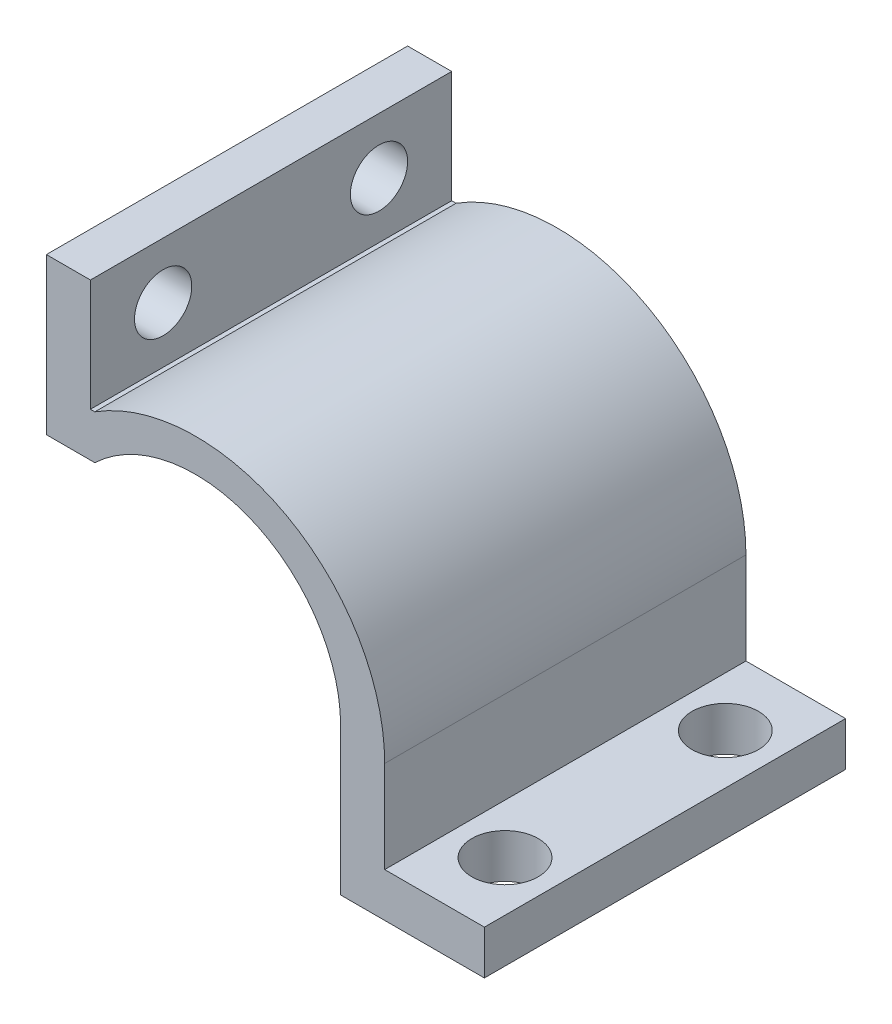
from build123d import *

# Parameters (mm, degrees)
BOSS_EXTRUDE1_DEPTH = 82
SKETCH3_R           = 7.537472245
CUT_EXTRUDE2_DEPTH  = 11
SKETCH4_R           = 6.5
CUT_EXTRUDE3_DEPTH  = 11


with BuildPart() as part:
    # Sketch1 → Boss-Extrude1 (new body)
    with BuildSketch(Plane.XY):
        with BuildLine():
            Line((33.003348812, 0), (33.003348812, -33.227979662))
            Line((33.003348812, -33.227979662), (65.632108119, -33.227979662))
            Line((65.632108119, -33.227979662), (65.632108119, -23.227979662))
            Line((65.632108119, -23.227979662), (43.003348812, -23.227979662))
            Line((43.003348812, -23.227979662), (43.003348812, -2.369569967))
            ThreePointArc((43.003348812, -2.369569967), (20.809611253, 35.186501293), (-22.793831907, 33.859768466))
            Line((-22.793831907, 33.859768466), (-23.793831907, 33.859768466))
            Line((-23.793831907, 33.859768466), (-23.793831907, 59.275147612))
            Line((-23.793831907, 59.275147612), (-33.793831907, 59.275147612))
            Line((-33.793831907, 59.275147612), (-33.793831907, 23.859768466))
            Line((-33.793831907, 23.859768466), (-22.793831907, 23.859768466))
            ThreePointArc((-22.793831907, 23.859768466), (12.978190551, 30.342272193), (33.003348812, 0))
        make_face()
    extrude(amount=-BOSS_EXTRUDE1_DEPTH)

    # Sketch3 → Cut-Extrude2 (cut, through all)
    with BuildSketch(Plane(origin=(0, -23.227979662, 0), x_dir=(1, 0, 0), z_dir=(0, 1, 0))):
        with Locations((54.317728466, 16)):
            Circle(SKETCH3_R)
        with Locations((54.317728466, 66)):
            Circle(SKETCH3_R)
    extrude(amount=-CUT_EXTRUDE2_DEPTH, mode=Mode.SUBTRACT)

    # Sketch4 → Cut-Extrude3 (cut, through all)
    with BuildSketch(Plane(origin=(-23.793831907, 0, 0), x_dir=(0, 0, -1), z_dir=(1, 0, 0))):
        with Locations((16.5, 46.567458039)):
            Circle(SKETCH4_R)
        with Locations((65.5, 46.567458039)):
            Circle(SKETCH4_R)
    extrude(amount=-CUT_EXTRUDE3_DEPTH, mode=Mode.SUBTRACT)


solid = part.part
